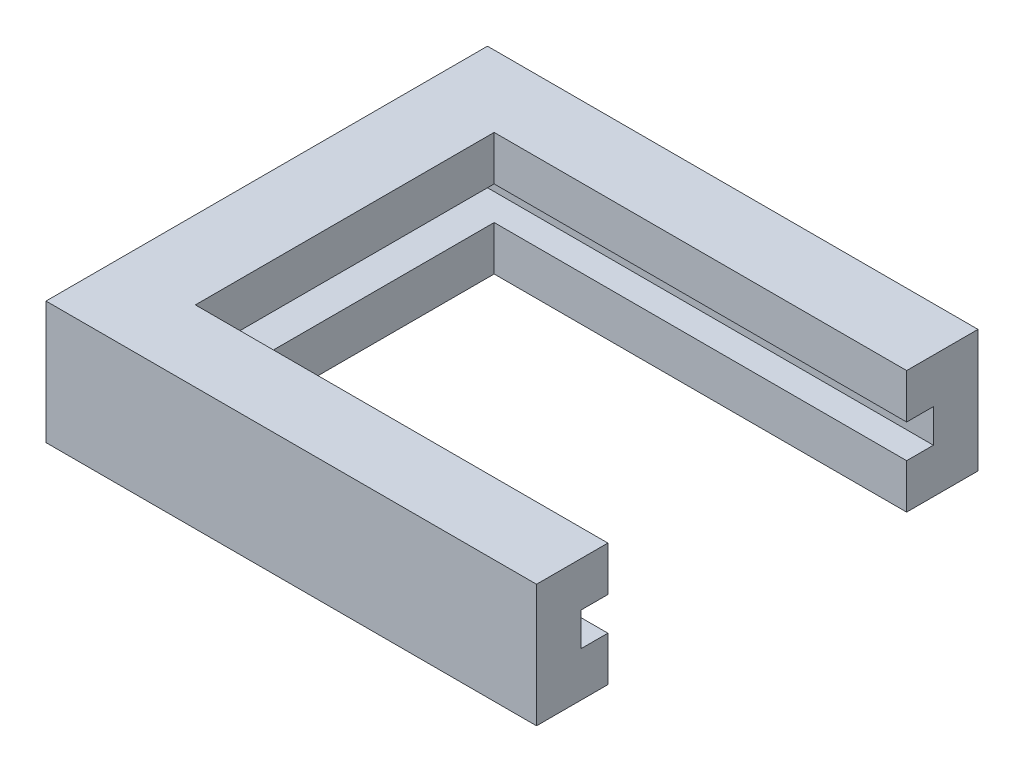
from build123d import *

# Parameters (mm, degrees)
SKETCH1_W           = 19.8
SKETCH1_H           = 5.5
SKETCH1_W_2         = 15.8
SKETCH1_H_2         = 1.5
BOSS_EXTRUDE1_DEPTH = 20.5
SKETCH2_W           = 18.5
SKETCH2_H           = 13.4
CUT_EXTRUDE1_DEPTH  = 6.5
SKETCH3_W           = 19.8
SKETCH3_H           = 5.5
BOSS_EXTRUDE2_DEPTH = 1.5


with BuildPart() as part:
    # Sketch1 → Boss-Extrude1 (new body)
    with BuildSketch(Plane(origin=(0, 0, 0), x_dir=(0, 0, -1), z_dir=(1, 0, 0))):
        with Locations((-4.788231672, 0.223036412)):
            Rectangle(SKETCH1_W, SKETCH1_H)
        with Locations((-4.788231672, 0.223036412)):
            Rectangle(SKETCH1_W_2, SKETCH1_H_2, mode=Mode.SUBTRACT)
    extrude(amount=BOSS_EXTRUDE1_DEPTH)

    # Sketch2 → Cut-Extrude1 (cut, through all)
    with BuildSketch(Plane(origin=(0, 2.973036412, 0), x_dir=(1, 0, 0), z_dir=(0, 1, 0))):
        with Locations((11.25, -4.788231672)):
            Rectangle(SKETCH2_W, SKETCH2_H)
    extrude(amount=-CUT_EXTRUDE1_DEPTH, mode=Mode.SUBTRACT)

    # Sketch3 → Boss-Extrude2 (add)
    with BuildSketch(Plane.ZY):
        with Locations((4.788231672, 0.223036412)):
            Rectangle(SKETCH3_W, SKETCH3_H)
    extrude(amount=BOSS_EXTRUDE2_DEPTH)


solid = part.part
